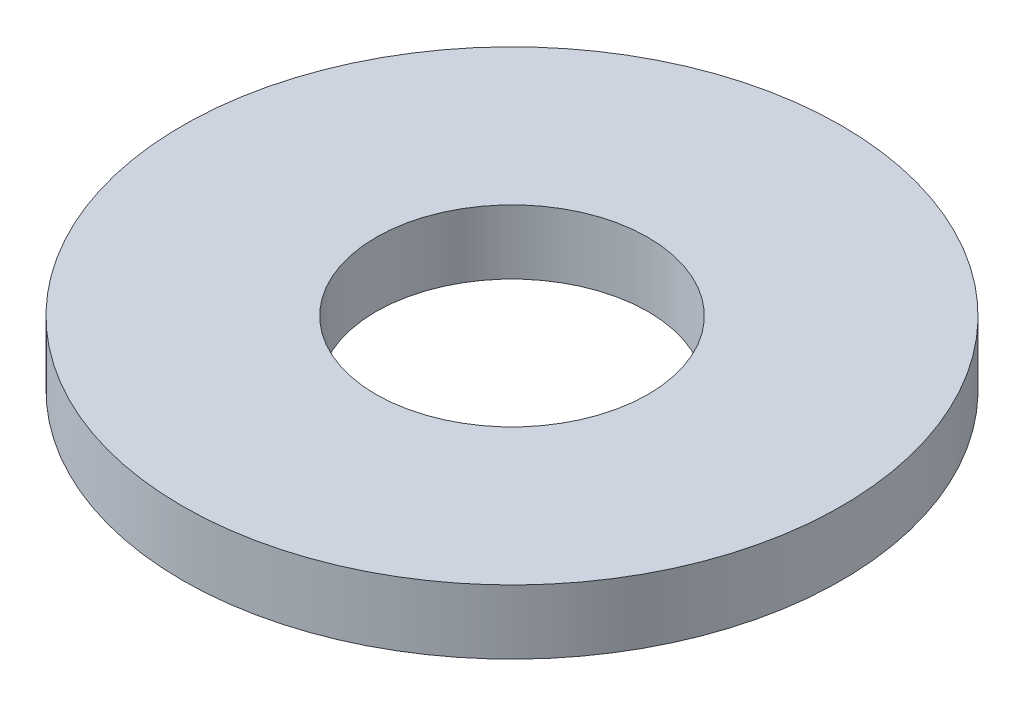
from build123d import *

# Parameters (mm, degrees)
SKETCH1_R           = 8
SKETCH1_R_2         = 3.302
BOSS_EXTRUDE1_DEPTH = 1.56


with BuildPart() as part:
    # Sketch1 → Boss-Extrude1 (new body)
    with BuildSketch(Plane(origin=(0, 0, 0), x_dir=(1, 0, 0), z_dir=(0, 1, 0))):
        Circle(SKETCH1_R)
        Circle(SKETCH1_R_2, mode=Mode.SUBTRACT)
    extrude(amount=BOSS_EXTRUDE1_DEPTH)


solid = part.part
